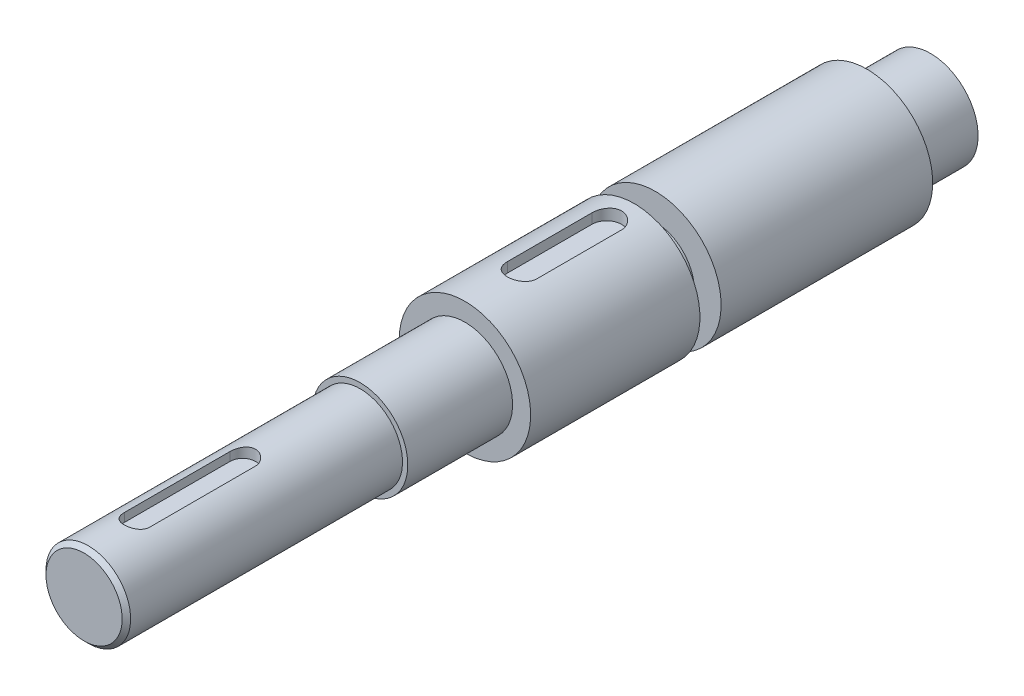
from build123d import *

# Parameters (mm, degrees)
CUT_EXTRUDE1_DEPTH  = 5
CUT_EXTRUDE12_DEPTH = 5.5
CHAMFER1_SIZE       = 2


with BuildPart() as part:
    # Sketch1 → Revolve1 (revolve)
    with BuildSketch(Plane(origin=(0, 0, 0), x_dir=(1, 0, 0), z_dir=(0, 1, 0))):
        Polygon((0, 0), (0, -400), (20, -400), (20, -269.514398681), (22.5, -269.514398681), (22.5, -220), (31.046216184, -220), (31.046216184, -140), (18.413082613, -140), (18.413082613, -130), (31.046216184, -130), (31.046216184, -30), (22.5, -30), (22.5, 0), align=None)
    revolve(axis=Axis((0, 0, 0), (0, 0, 1)))

    # Sketch3 → Cut-Extrude1 (cut)
    with BuildSketch(Plane(origin=(0, 20, 400), x_dir=(0, 0, 1), z_dir=(0, -1, 0))):
        with BuildLine():
            Line((-25, 6), (-75, 6))
            ThreePointArc((-75, 6), (-81, 0), (-75, -6))
            Line((-75, -6), (-25, -6))
            ThreePointArc((-25, -6), (-19, 0), (-25, 6))
        make_face()
    extrude(amount=CUT_EXTRUDE1_DEPTH, mode=Mode.SUBTRACT)

    # Sketch32 → Cut-Extrude12 (cut)
    with BuildSketch(Plane(origin=(0, 31.046216184, 220), x_dir=(0, 0, 1), z_dir=(0, -1, 0))):
        with BuildLine():
            Line((-27, 7), (-67, 7))
            ThreePointArc((-67, 7), (-74, 0), (-67, -7))
            Line((-67, -7), (-27, -7))
            ThreePointArc((-27, -7), (-20, 0), (-27, 7))
        make_face()
    extrude(amount=CUT_EXTRUDE12_DEPTH, mode=Mode.SUBTRACT)

    # Chamfer1
    chamfer1_edges = [part.edges().sort_by_distance(p)[0] for p in [
        (-20, 0, 400),
    ]]
    chamfer(chamfer1_edges, length=CHAMFER1_SIZE)


solid = part.part
